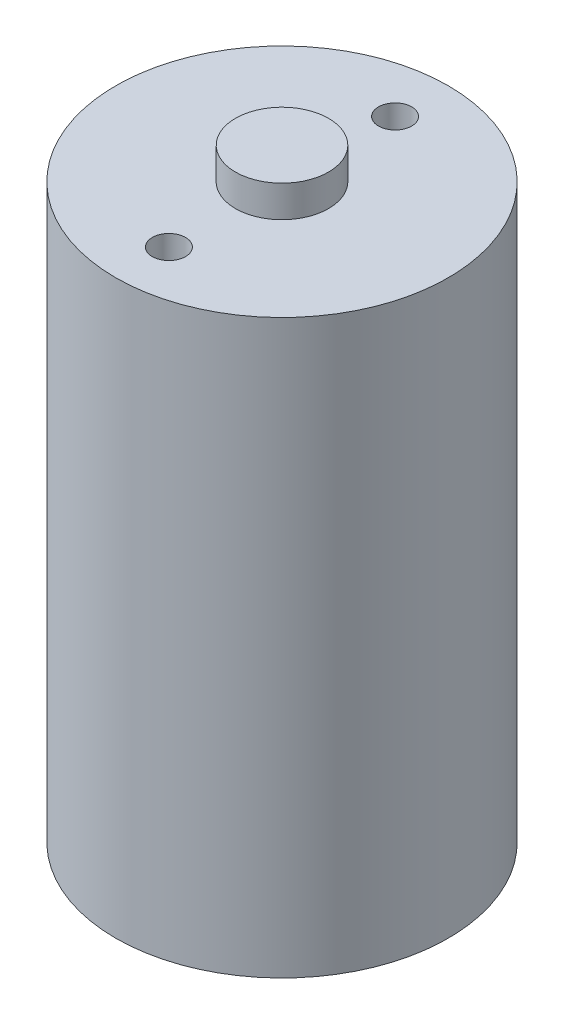
from build123d import *

# Parameters (mm, degrees)
SKETCH1_R           = 12.5
BOSS_EXTRUDE1_DEPTH = 43
SKETCH2_R           = 3.5
BOSS_EXTRUDE2_DEPTH = 2.38
SKETCH3_R           = 1.25
CUT_EXTRUDE1_DEPTH  = 4


with BuildPart() as part:
    # Sketch1 → Boss-Extrude1 (new body)
    with BuildSketch(Plane(origin=(0, 0, 0), x_dir=(1, 0, 0), z_dir=(0, 1, 0))):
        Circle(SKETCH1_R)
    extrude(amount=BOSS_EXTRUDE1_DEPTH)

    # Sketch2 → Boss-Extrude2 (add)
    with BuildSketch(Plane(origin=(0, 43, 0), x_dir=(1, 0, 0), z_dir=(0, 1, 0))):
        Circle(SKETCH2_R)
    extrude(amount=BOSS_EXTRUDE2_DEPTH)

    # Sketch3 → Cut-Extrude1 (cut)
    with BuildSketch(Plane(origin=(0, 43, 0), x_dir=(1, 0, 0), z_dir=(0, 1, 0))):
        with Locations((0, 8.5)):
            Circle(SKETCH3_R)
        with Locations((0, -8.5)):
            Circle(SKETCH3_R)
    extrude(amount=-CUT_EXTRUDE1_DEPTH, mode=Mode.SUBTRACT)


solid = part.part
